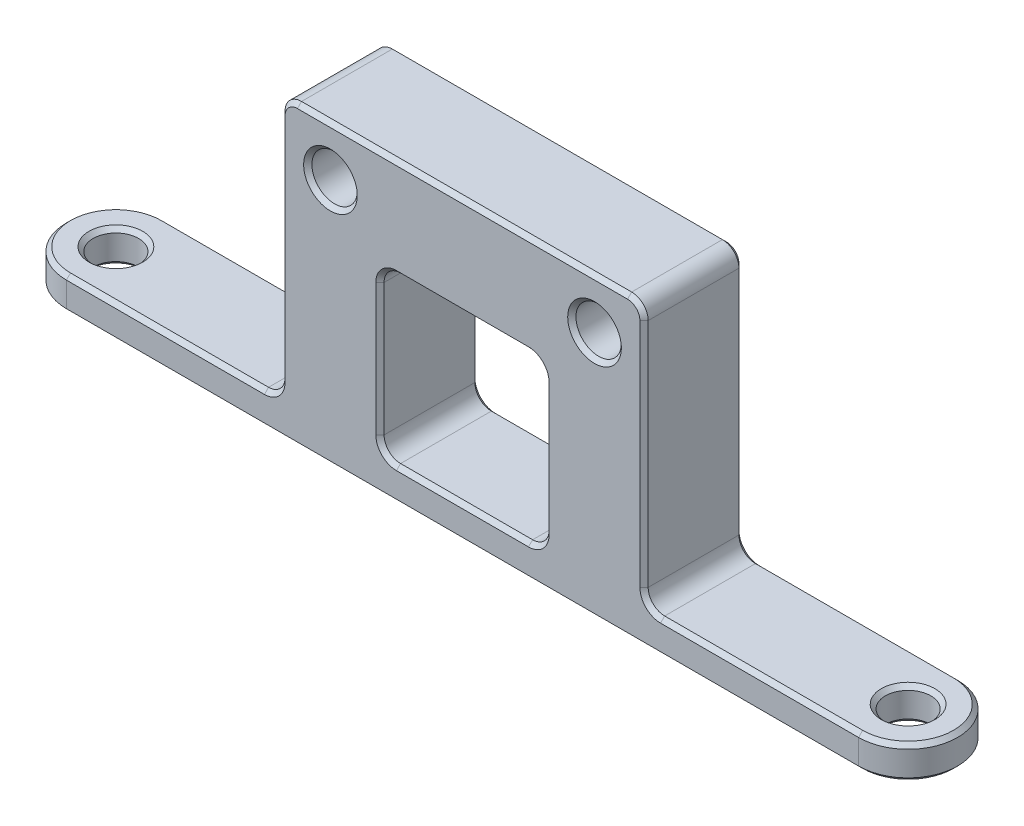
from build123d import *

# Parameters (mm, degrees)
SKETCH2_R               = 2.1828125
BOSS_EXTRUDE1_DEPTH     = 3.175
SKETCH3_W               = 36.843225838
SKETCH3_H               = 9.525
BOSS_EXTRUDE2_DEPTH     = 25.4
SKETCH4_R               = 2.1828125
SKETCH4_W               = 0.959112919
SKETCH4_H               = 25.4
SKETCH4_W_2             = 15.875
SKETCH4_H_2             = 15.875
CUT_EXTRUDE1_DEPTH      = 1
CUT_EXTRUDE1_DEPTH_BACK = 10.525
FILLET1_R               = 1.5875
CHAMFER1_SIZE           = 0.396875


with BuildPart() as part:
    # Sketch2 → Boss-Extrude1 (new body)
    with BuildSketch(Plane(origin=(0, 0, 0), x_dir=(1, 0, 0), z_dir=(0, 1, 0))):
        with BuildLine():
            Line((-38.1, 4.7625), (38.1, 4.7625))
            ThreePointArc((38.1, 4.7625), (42.8625, 0), (38.1, -4.7625))
            Line((38.1, -4.7625), (-38.1, -4.7625))
            ThreePointArc((-38.1, -4.7625), (-42.8625, 0), (-38.1, 4.7625))
        make_face()
        with Locations((-38.1, 0)):
            Circle(SKETCH2_R, mode=Mode.SUBTRACT)
        with Locations((38.1, 0)):
            Circle(SKETCH2_R, mode=Mode.SUBTRACT)
    extrude(amount=BOSS_EXTRUDE1_DEPTH)

    # Sketch3 → Boss-Extrude2 (add)
    with BuildSketch(Plane(origin=(0, 3.175, 0), x_dir=(1, 0, 0), z_dir=(0, 1, 0))):
        Rectangle(SKETCH3_W, SKETCH3_H)
    extrude(amount=BOSS_EXTRUDE2_DEPTH)

    # Sketch4 → Cut-Extrude1 (cut, two sides)
    with BuildSketch(Plane.XY.offset(4.7625)) as cut_extrude1_sk:
        with Locations((-12.7, 23.8125)):
            Circle(SKETCH4_R)
        with Locations((12.7, 23.8125)):
            Circle(SKETCH4_R)
        with Locations((-17.94205646, 15.875)):
            Rectangle(SKETCH4_W, SKETCH4_H)
        with Locations((17.94205646, 15.875)):
            Rectangle(SKETCH4_W, SKETCH4_H)
        with Locations((0, 11.1125)):
            Rectangle(SKETCH4_W_2, SKETCH4_H_2)
    extrude(amount=CUT_EXTRUDE1_DEPTH, mode=Mode.SUBTRACT)
    extrude(cut_extrude1_sk.sketch, amount=-CUT_EXTRUDE1_DEPTH_BACK, mode=Mode.SUBTRACT)

    # Fillet1
    fillet1_edges = [part.edges().sort_by_distance(p)[0] for p in [
        (-17.4625, 3.175, 0),
        (-17.4625, 28.575, 0),
        (17.4625, 28.575, 0),
        (17.4625, 3.175, 0),
        (-7.9375, 3.175, 0),
        (-7.9375, 19.05, 0),
        (7.9375, 19.05, 0),
        (7.9375, 3.175, 0),
    ]]
    fillet(fillet1_edges, radius=FILLET1_R)

    # Chamfer1
    chamfer1_edges = [part.edges().sort_by_distance(p)[0] for p in [
        (0, 28.575, -4.7625),
        (0, 28.575, 4.7625),
        (0, 3.175, 4.7625),
        (-7.9375, 11.1125, 4.7625),
        (0, 19.05, 4.7625),
        (7.9375, 11.1125, 4.7625),
        (-17.4625, 15.875, 4.7625),
        (28.575, 3.175, 4.7625),
        (17.4625, 15.875, 4.7625),
        (16.997532015, 28.110032015, 4.7625),
        (-16.997532015, 28.110032015, 4.7625),
        (-17.4625, 15.875, -4.7625),
        (0, 19.05, -4.7625),
        (-7.9375, 11.1125, -4.7625),
        (0, 3.175, -4.7625),
        (7.9375, 11.1125, -4.7625),
        (-28.575, 3.175, -4.7625),
        (17.4625, 15.875, -4.7625),
        (16.997532015, 28.110032015, -4.7625),
        (-16.997532015, 28.110032015, -4.7625),
        (-40.2828125, 0, 0),
        (-17.927467985, 3.639967985, 4.7625),
        (-40.2828125, 3.175, 0),
        (-17.927467985, 3.639967985, -4.7625),
        (17.927467985, 3.639967985, 4.7625),
        (17.927467985, 3.639967985, -4.7625),
        (-7.472532015, 18.585032015, 4.7625),
        (42.8625, 3.175, 0),
        (-7.472532015, 18.585032015, -4.7625),
        (7.472532015, 18.585032015, 4.7625),
        (7.472532015, 18.585032015, -4.7625),
        (7.472532015, 3.639967985, 4.7625),
        (7.472532015, 3.639967985, -4.7625),
        (-7.472532015, 3.639967985, 4.7625),
        (-7.472532015, 3.639967985, -4.7625),
        (35.9171875, 0, 0),
        (35.9171875, 3.175, 0),
        (28.575, 3.175, -4.7625),
        (10.5171875, 23.8125, -4.7625),
        (10.5171875, 23.8125, 4.7625),
        (-42.8625, 3.175, 0),
        (0, 0, -4.7625),
        (42.8625, 0, 0),
        (0, 0, 4.7625),
        (-42.8625, 0, 0),
        (-14.8828125, 23.8125, -4.7625),
        (-14.8828125, 23.8125, 4.7625),
        (-28.575, 3.175, 4.7625),
    ]]
    chamfer(chamfer1_edges, length=CHAMFER1_SIZE)


solid = part.part
